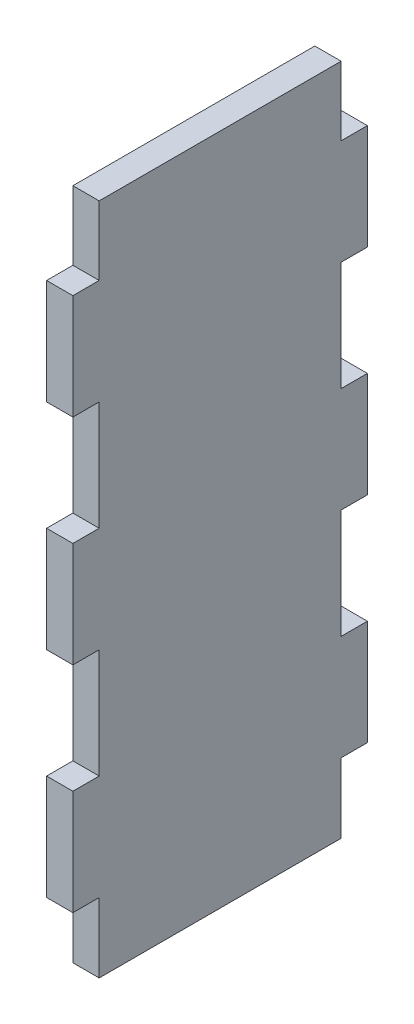
from build123d import *

# Parameters (mm, degrees)
SKETCH1_W          = 35.56
SKETCH1_H          = 90.932
EXTRUDE1_DEPTH     = 3.175
SKETCH2_W          = 3.175
SKETCH2_H          = 13.208
CUT_EXTRUDE1_DEPTH = 4.175
SKETCH3_W          = 3.175
SKETCH3_H          = 4.885047255
SKETCH3_H_2        = 4.792331668
CUT_EXTRUDE2_DEPTH = 33.385


with BuildPart() as part:
    # Sketch1 → Extrude1 (new body)
    with BuildSketch(Plane(origin=(0, 0, 0), x_dir=(0, 0, -1), z_dir=(1, 0, 0))):
        Rectangle(SKETCH1_W, SKETCH1_H)
    extrude(amount=EXTRUDE1_DEPTH)

    # Sketch2 → Cut-Extrude1 (cut, through all)
    with BuildSketch(Plane(origin=(3.175, 0, 0), x_dir=(0, 0, -1), z_dir=(1, 0, 0))):
        with Locations((-16.1925, 38.862)):
            Rectangle(SKETCH2_W, SKETCH2_H)
        with Locations((-16.1925, 12.954)):
            Rectangle(SKETCH2_W, SKETCH2_H)
        with Locations((-16.1925, -12.954)):
            Rectangle(SKETCH2_W, SKETCH2_H)
        with Locations((-16.1925, -38.862)):
            Rectangle(SKETCH2_W, SKETCH2_H)
        with Locations((-16.1925, -64.77)):
            Rectangle(SKETCH2_W, SKETCH2_H)
        with Locations((16.1925, -38.862)):
            Rectangle(SKETCH2_W, SKETCH2_H)
        with Locations((16.1925, -12.954)):
            Rectangle(SKETCH2_W, SKETCH2_H)
        with Locations((16.1925, 12.954)):
            Rectangle(SKETCH2_W, SKETCH2_H)
        with Locations((16.1925, 38.862)):
            Rectangle(SKETCH2_W, SKETCH2_H)
    extrude(amount=-CUT_EXTRUDE1_DEPTH, mode=Mode.SUBTRACT)

    # Sketch3 → Cut-Extrude2 (cut, through all)
    with BuildSketch(Plane.XY.offset(14.605)):
        with Locations((1.5875, 43.023476372)):
            Rectangle(SKETCH3_W, SKETCH3_H)
        with Locations((1.5875, -43.069834166)):
            Rectangle(SKETCH3_W, SKETCH3_H_2)
    extrude(amount=-CUT_EXTRUDE2_DEPTH, mode=Mode.SUBTRACT)


solid = part.part
